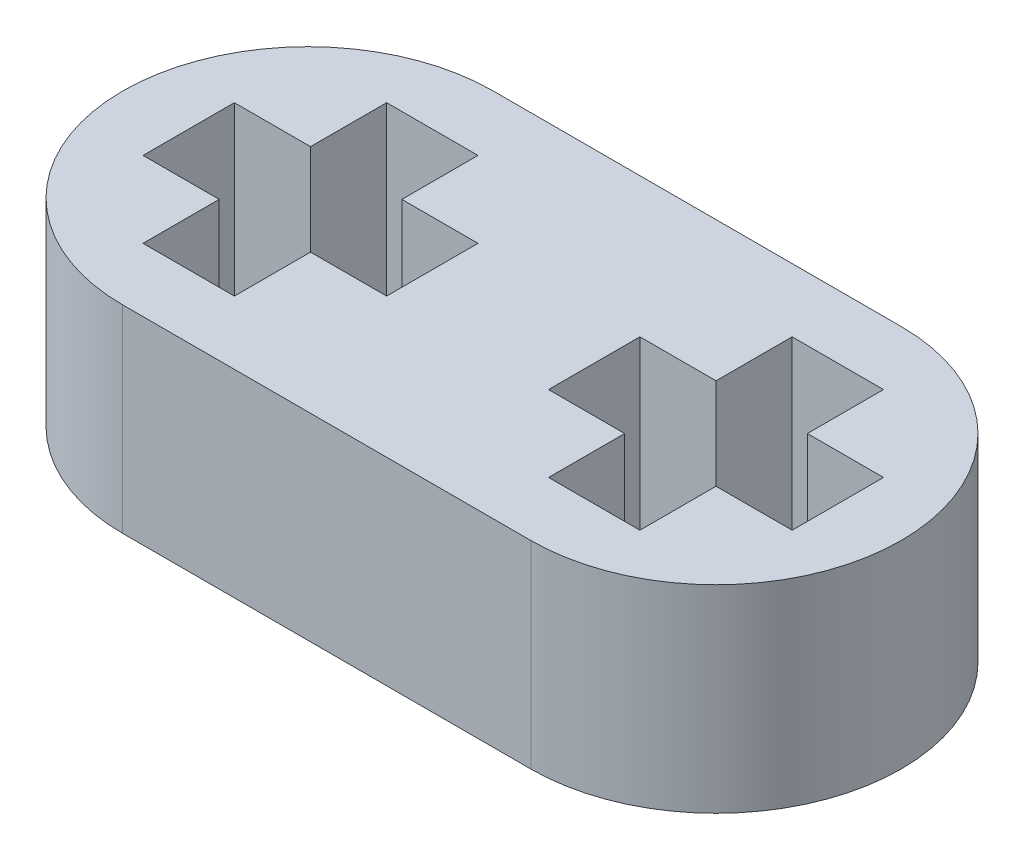
from build123d import *

# Parameters (mm, degrees)
BOSS_EXTRUDE1_DEPTH = 3.9


with BuildPart() as part:
    # Sketch1 → Boss-Extrude1 (new body)
    with BuildSketch(Plane(origin=(0, 0, 0), x_dir=(1, 0, 0), z_dir=(0, 1, 0))):
        with BuildLine():
            Line((-4.02, 3.65), (4.02, 3.65))
            ThreePointArc((4.02, 3.65), (7.67, 0), (4.02, -3.65))
            Line((4.02, -3.65), (-4.02, -3.65))
            ThreePointArc((-4.02, -3.65), (-7.67, 0), (-4.02, 3.65))
        make_face()
        Polygon((3.12, 2.4), (3.12, 0.9), (1.62, 0.9), (1.62, -0.9), (3.12, -0.9), (3.12, -2.4), (4.92, -2.4), (4.92, -0.9), (6.42, -0.9), (6.42, 0.9), (4.92, 0.9), (4.92, 2.4), align=None, mode=Mode.SUBTRACT)
        Polygon((-4.870347538, 2.400403287), (-4.870347538, 0.900403287), (-6.370347538, 0.900403287), (-6.370347538, -0.899596713), (-4.870347538, -0.899596713), (-4.870347538, -2.399596713), (-3.070347538, -2.399596713), (-3.070347538, -0.899596713), (-1.570347538, -0.899596713), (-1.570347538, 0.900403287), (-3.070347538, 0.900403287), (-3.070347538, 2.400403287), align=None, mode=Mode.SUBTRACT)
    extrude(amount=BOSS_EXTRUDE1_DEPTH)


solid = part.part
